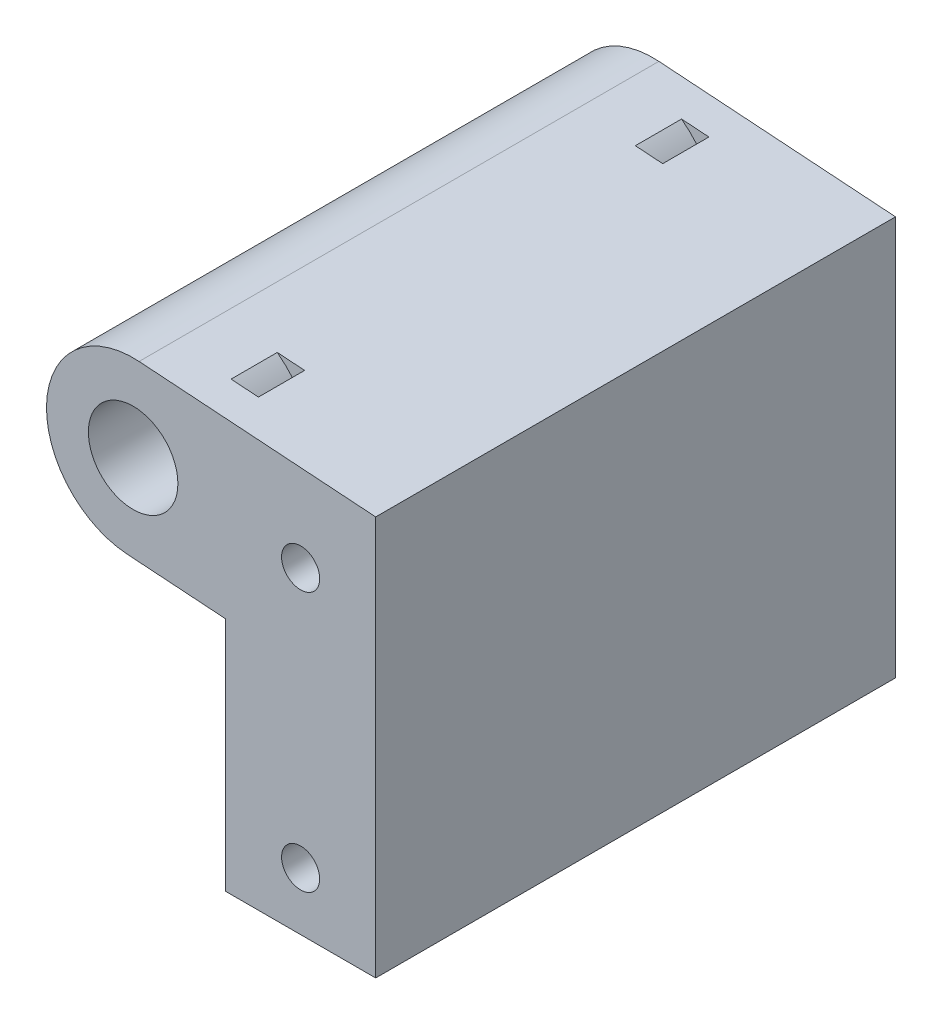
from build123d import *

# Parameters (mm, degrees)
BOSS_EXTRUDE1_DEPTH   = 45
CUT_EXTRUDE1_START    = -5
CUT_EXTRUDE1_DEPTH    = 2
M4X0_7_TAPPED_HOLE1_D = 3.3
SKETCH5_R             = 7.5
BOSS_EXTRUDE2_DEPTH   = 45
SKETCH6_R             = 3.875
CUT_EXTRUDE2_DEPTH    = 46


with BuildPart() as part:
    # Sketch1 → Boss-Extrude1 (new body)
    with BuildSketch(Plane.XY):
        with BuildLine():
            Line((-182.516015687, 162.517772537), (-174, 161.93046111))
            Line((-174, 161.93046111), (-174, 141.5))
            Line((-174, 141.5), (-161, 141.5))
            Line((-161, 141.5), (-161, 176.06953889))
            Line((-161, 176.06953889), (-181.483984313, 177.482227463))
            ThreePointArc((-181.483984313, 177.482227463), (-174.517772537, 169.483984313), (-182.516015687, 162.517772537))
        make_face()
    extrude(amount=BOSS_EXTRUDE1_DEPTH)

    # Sketch2 → Cut-Extrude1 (cut, symmetric)
    with BuildSketch(Plane(origin=(0, 0, 0), x_dir=(-1, 0, 0), z_dir=(0, 0, -1)).offset(CUT_EXTRUDE1_START)):
        with BuildLine():
            ThreePointArc((176.520836095, 177.139941379), (173.021327044, 169.380781175), (177.552867469, 162.175486453))
            ThreePointArc((177.552867469, 162.175486453), (177.834315887, 161.15284928), (176.811678714, 160.871400862))
            ThreePointArc((176.811678714, 160.871400862), (171.524881552, 169.277578038), (175.60764211, 178.329931609))
            ThreePointArc((175.60764211, 178.329931609), (176.659234217, 178.191533486), (176.520836095, 177.139941379))
        make_face()
    cut_extrude1 = extrude(amount=CUT_EXTRUDE1_DEPTH, both=True, mode=Mode.SUBTRACT)

    # Mirror1: Cut-Extrude1 across plane
    add(cut_extrude1.mirror(Plane(origin=(0, 0, 22.5), x_dir=(1, 0, 0), z_dir=(0, 0, -1))), mode=Mode.SUBTRACT)

    # M4x0.7 Tapped Hole1 (through all)
    with Locations(Plane.XY.offset(45)):
        with Locations((-167.5, 169), (-167.5, 146.5)):
            Hole(M4X0_7_TAPPED_HOLE1_D / 2)

    # Sketch5 → Boss-Extrude2 (add, through all)
    with BuildSketch(Plane.XY.offset(45)):
        with Locations((-182, 170)):
            Circle(SKETCH5_R)
    extrude(amount=-BOSS_EXTRUDE2_DEPTH)

    # Sketch6 → Cut-Extrude2 (cut, through all)
    with BuildSketch(Plane.XY.offset(45)):
        with Locations((-182, 170)):
            Circle(SKETCH6_R)
    extrude(amount=-CUT_EXTRUDE2_DEPTH, mode=Mode.SUBTRACT)

    # Sketch9 → Cut-Revolve1 (revolve, cut)
    with BuildSketch(Plane(origin=(10.807100592, 156.70295858, 0), x_dir=(-0.997630328, 0.068802092, 0), z_dir=(-0.068802092, -0.997630328, 0))):
        Polygon((189.390075348, -9), (187.890075348, -12.5), (189.390075348, -16), align=None)
        Polygon((189.390075348, -19), (189.390075348, -26), (187.890075348, -22.5), align=None)
        Polygon((189.390075348, -29), (189.390075348, -36), (187.890075348, -32.5), align=None)
    revolve(axis=Axis((-182, 170, 0), (0, 0, 1)), mode=Mode.SUBTRACT)


solid = part.part
